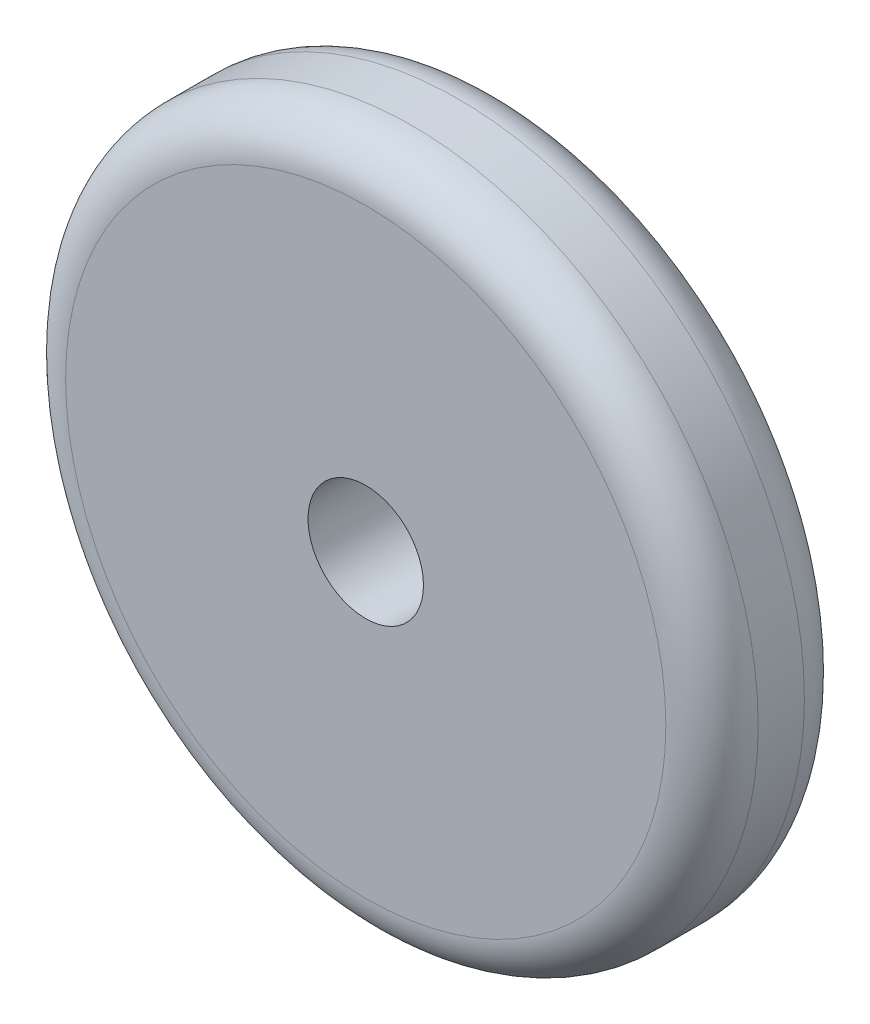
from build123d import *

# Parameters (mm, degrees)
CROQUIS1_R              = 15
CROQUIS1_R_2            = 2.5
SALIENTE_EXTRUIR1_DEPTH = 6
REDONDEO1_R             = 2


with BuildPart() as part:
    # Croquis1 → Saliente-Extruir1 (new body)
    with BuildSketch(Plane.XY):
        Circle(CROQUIS1_R)
        Circle(CROQUIS1_R_2, mode=Mode.SUBTRACT)
    extrude(amount=SALIENTE_EXTRUIR1_DEPTH)

    # Redondeo1
    redondeo1_edges = [part.edges().sort_by_distance(p)[0] for p in [
        (-15, 0, 0),
        (-15, 0, 6),
    ]]
    fillet(redondeo1_edges, radius=REDONDEO1_R)


solid = part.part
